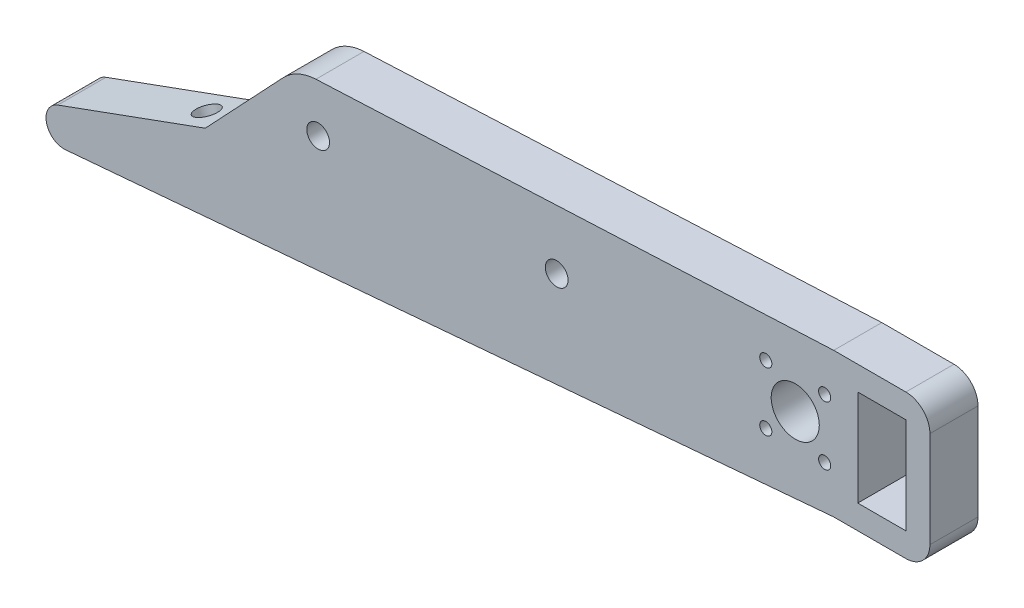
from build123d import *

# Parameters (mm, degrees)
SKETCH1_R           = 3.175
SKETCH1_R_2         = 0.8
SKETCH1_R_3         = 1.499997
SKETCH1_W           = 6.35
SKETCH1_H           = 12.7
BOSS_EXTRUDE1_DEPTH = 3.175
FILLET1_R           = 3.175
SKETCH2_R           = 1.5
CUT_EXTRUDE1_DEPTH  = 6


with BuildPart() as part:
    # Sketch1 → Boss-Extrude1 (new body, symmetric)
    with BuildSketch(Plane.XY):
        with BuildLine():
            Line((36.576, 9.525), (49.276, 9.525))
            Line((49.276, 9.525), (49.276, -9.525))
            Line((49.276, -9.525), (36.576, -9.525))
            Line((36.576, -9.525), (-64.842812423, -18.25625))
            ThreePointArc((-64.842812423, -18.25625), (-67.372222956, -16.397560002), (-65.861496639, -13.646132709))
            Line((-65.861496639, -13.646132709), (-46.397973184, -6.561989517))
            Line((-46.397973184, -6.561989517), (-36.118832942, 4.353379789))
            ThreePointArc((-36.118832942, 4.353379789), (-34.148654973, 5.769395254), (-31.791214639, 6.343133951))
            Line((-31.791214639, 6.343133951), (36.576, 9.525))
        make_face()
        with Locations((31.496, 0)):
            Circle(SKETCH1_R, mode=Mode.SUBTRACT)
        with Locations((27.606912703, 3.889087297)):
            Circle(SKETCH1_R_2, mode=Mode.SUBTRACT)
        with Locations((35.385087297, -3.889087297)):
            Circle(SKETCH1_R_2, mode=Mode.SUBTRACT)
        with Locations((-31.496, 0)):
            Circle(SKETCH1_R_3, mode=Mode.SUBTRACT)
        with Locations((35.385087297, 3.889087297)):
            Circle(SKETCH1_R_2, mode=Mode.SUBTRACT)
        with Locations((27.606912703, -3.889087297)):
            Circle(SKETCH1_R_2, mode=Mode.SUBTRACT)
        Circle(SKETCH1_R_3, mode=Mode.SUBTRACT)
        with Locations((42.926, 0)):
            Rectangle(SKETCH1_W, SKETCH1_H, mode=Mode.SUBTRACT)
    extrude(amount=BOSS_EXTRUDE1_DEPTH, both=True)

    # Fillet1
    fillet1_edges = [part.edges().sort_by_distance(p)[0] for p in [
        (49.276, 9.525, 0),
        (49.276, -9.525, 0),
    ]]
    fillet(fillet1_edges, radius=FILLET1_R)

    # Sketch2 → Cut-Extrude1 (cut)
    with BuildSketch(Plane(origin=(-3.318549049, 9.117638577, 0), x_dir=(0.939692621, 0.342020143, 0), z_dir=(-0.342020143, 0.939692621, 0))):
        with Locations((-49.019165615, 0)):
            Circle(SKETCH2_R)
    extrude(amount=-CUT_EXTRUDE1_DEPTH, mode=Mode.SUBTRACT)


solid = part.part
